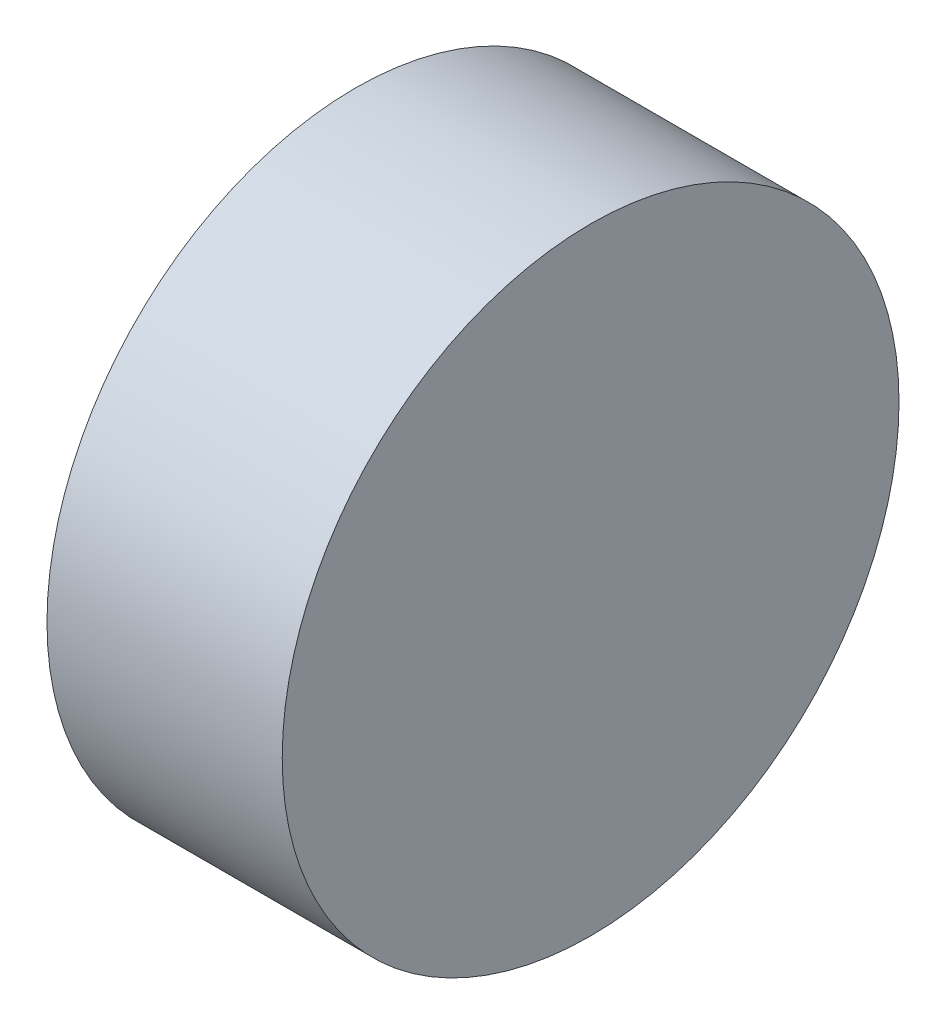
from build123d import *

# Parameters (mm, degrees)
SKETCH1_R                = 33.3
BOSS_EXTRUDE1_DEPTH      = 12.7
BOSS_EXTRUDE1_DEPTH_BACK = 12.7


with BuildPart() as part:
    # Sketch1 → Boss-Extrude1 (new body, two sides)
    with BuildSketch(Plane(origin=(0, 0, 0), x_dir=(0, 0, -1), z_dir=(1, 0, 0))) as boss_extrude1_sk:
        Circle(SKETCH1_R)
    extrude(amount=BOSS_EXTRUDE1_DEPTH)
    extrude(boss_extrude1_sk.sketch, amount=-BOSS_EXTRUDE1_DEPTH_BACK)


solid = part.part
